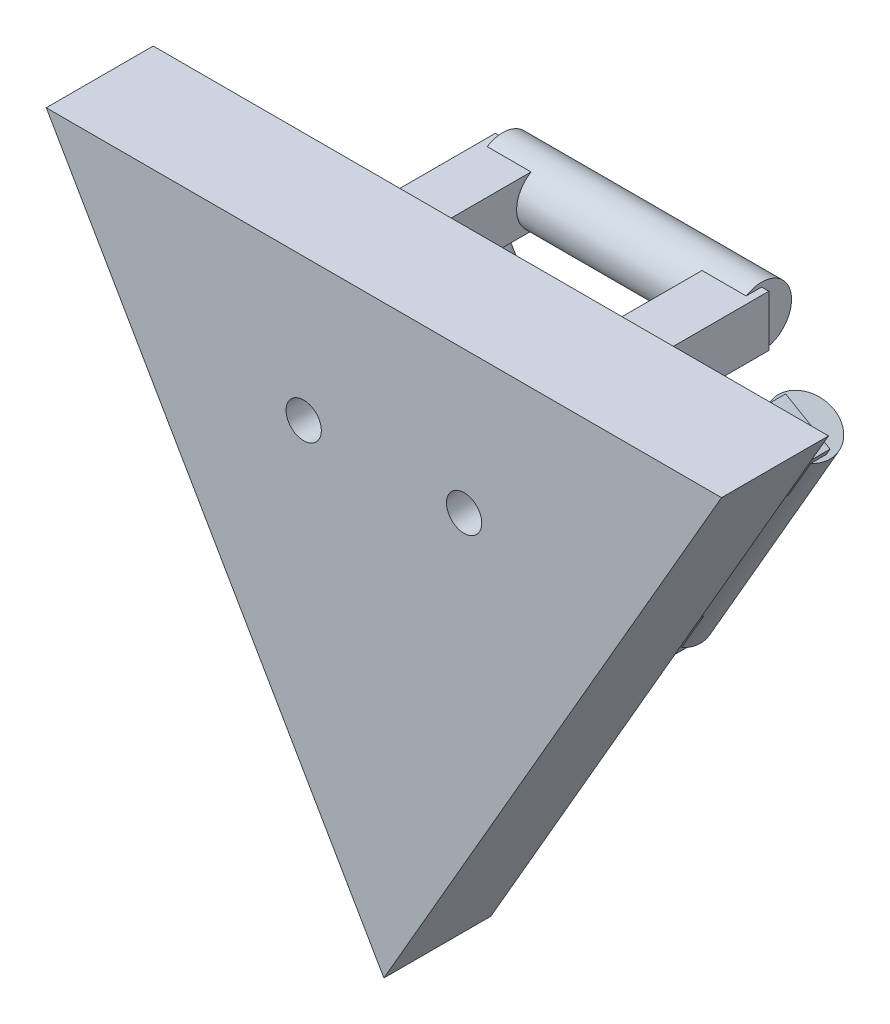
from build123d import *

# Parameters (mm, degrees)
EXTRUDE_1_DEPTH        = 10
EXTRUDE_2_DEPTH        = 13.2
EXTRUDE_3_DEPTH        = 20.1058285
EXTRUDE_3_DEPTH_BACK   = 4
SKETCH_3_R             = 2.8
EXTRUDE_4_DEPTH        = 20.1058285
EXTRUDE_4_DEPTH_BACK   = 4.1058285
SKETCH_4_R             = 2.8
EXTRUDE_5_DEPTH        = 20.1058285
EXTRUDE_5_DEPTH_BACK   = 4.1058285
SKETCH_5_R             = 2.8
HOLE_WIZARD_M4_1_D     = 3.3
HOLE_WIZARD_M4_1_DEPTH = 10.1
HOLE_WIZARD_M4_1_TIP   = 0.991420021


with BuildPart() as part:
    # 草图1 → 凸台-拉伸1 (new body)
    with BuildSketch(Plane.XY):
        Polygon((-31.572352781, 18.279290669), (0, -36.405628463), (31.572352781, 18.279290669), align=None)
    extrude(amount=EXTRUDE_1_DEPTH)

    # 草图1<5> → 凸台-拉伸2 (add)
    with BuildSketch(Plane.XY):
        Polygon((11.960518161, 2.321180547), (14.039474758, 1.120894396), (16.117440099, -0.078819453), (18.517440099, 4.078102485), (14.360518161, 6.478102485), align=None)
        Polygon((-7.990460401, 9.197522296), (-7.990460401, 12.000572743), (-7.990460401, 13.997522296), (-12.790460401, 13.997522296), (-12.790460401, 9.197522296), align=None)
        Polygon((7.990460401, 14.002477704), (7.990460401, 12.004383545), (7.990460401, 9.202477704), (12.790460401, 9.202477704), (12.790460401, 14.002477704), align=None)
        Polygon((8.131271207, -13.921180547), (6.052314609, -12.720894396), (3.974349269, -11.521180547), (1.574349269, -15.678102485), (5.731271207, -18.078102485), align=None)
        Polygon((-3.97005776, -11.518702843), (-6.395424519, -12.918988994), (-8.126979698, -13.918702843), (-5.726979698, -18.075624781), (-1.57005776, -15.675624781), align=None)
        Polygon((-18.521731608, 4.075624781), (-16.121731608, -0.081297157), (-14.389185172, 0.918988994), (-11.96480967, 2.318702843), (-14.36480967, 6.475624781), align=None)
    extrude(amount=-EXTRUDE_2_DEPTH)

    # 草图3 → 凸台-拉伸3 (add, two sides: drawn at the far end of the back side and taken through both)
    with BuildSketch(Plane(origin=(3.9952302, -6.919941695, 0), x_dir=(0.8660254037844364, 0.5000000000000041, 0), z_dir=(-0.500000000000004, 0.8660254037844363, 0)).offset(-EXTRUDE_3_DEPTH_BACK)):
        with Locations((-11.602477704, 13.2)):
            Circle(SKETCH_3_R)
    extrude(amount=EXTRUDE_3_DEPTH + EXTRUDE_3_DEPTH_BACK)

    # 草图4 → 凸台-拉伸4 (add, two sides: drawn at the far end of the back side and taken through both)
    with BuildSketch(Plane(origin=(-7.990460401, 0, 0), x_dir=(0, 0, -1), z_dir=(1, 0, 0)).offset(-EXTRUDE_4_DEPTH_BACK)):
        with Locations((13.2, 11.602477704)):
            Circle(SKETCH_4_R)
    extrude(amount=EXTRUDE_4_DEPTH + EXTRUDE_4_DEPTH_BACK)

    # 草图5 → 凸台-拉伸5 (add, two sides: drawn at the far end of the back side and taken through both)
    with BuildSketch(Plane(origin=(3.9952302, 6.919941695, 0), x_dir=(-0.8660254037844365, 0.5000000000000039, 0), z_dir=(-0.5000000000000038, -0.8660254037844364, 0)).offset(-EXTRUDE_5_DEPTH_BACK)):
        with Locations((-11.602477704, 13.2)):
            Circle(SKETCH_5_R)
    extrude(amount=EXTRUDE_5_DEPTH + EXTRUDE_5_DEPTH_BACK)

    # M4 螺纹孔1
    with Locations(Plane.XY.offset(10)):
        with Locations((7.5, 5), (-7.5, 5)):
            Hole(HOLE_WIZARD_M4_1_D / 2, depth=HOLE_WIZARD_M4_1_DEPTH)
            with Locations((0, 0, -(HOLE_WIZARD_M4_1_DEPTH + HOLE_WIZARD_M4_1_TIP / 2))):  # 118° drill point
                Cone(0, HOLE_WIZARD_M4_1_D / 2, HOLE_WIZARD_M4_1_TIP, mode=Mode.SUBTRACT)


solid = part.part
